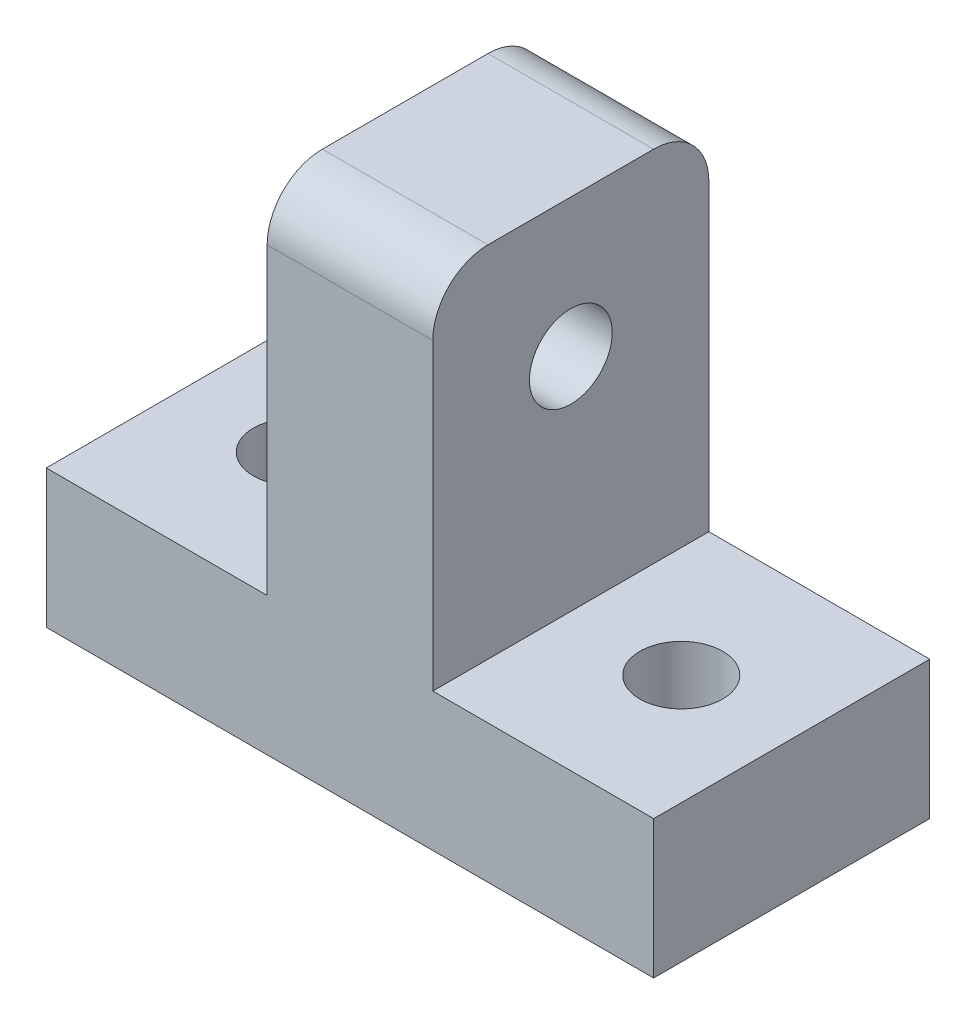
from build123d import *

# Parameters (mm, degrees)
SKETCH1_W           = 22
SKETCH1_H           = 10
SKETCH1_R           = 1.5
BOSS_EXTRUDE1_DEPTH = 5
SKETCH4_W           = 6
SKETCH4_H           = 10
BOSS_EXTRUDE3_DEPTH = 13
CUT_EXTRUDE1_REACH  = 16
SKETCH5_R           = 1.5
FILLET1_R           = 2


with BuildPart() as part:
    # Sketch1 → Boss-Extrude1 (new body)
    with BuildSketch(Plane(origin=(0, 0, 0), x_dir=(1, 0, 0), z_dir=(0, 1, 0))):
        Rectangle(SKETCH1_W, SKETCH1_H)
        with Locations((-7, 0)):
            Circle(SKETCH1_R, mode=Mode.SUBTRACT)
        with Locations((7, 0)):
            Circle(SKETCH1_R, mode=Mode.SUBTRACT)
    extrude(amount=BOSS_EXTRUDE1_DEPTH)

    # Sketch4 → Boss-Extrude3 (add)
    with BuildSketch(Plane(origin=(0, 5, 0), x_dir=(1, 0, 0), z_dir=(0, 1, 0))):
        Rectangle(SKETCH4_W, SKETCH4_H)
    extrude(amount=BOSS_EXTRUDE3_DEPTH)

    # Sketch5 → Cut-Extrude1 (cut, up to next)
    with BuildSketch(Plane(origin=(3, 0, 0), x_dir=(0, 0, -1), z_dir=(1, 0, 0)), mode=Mode.PRIVATE) as cut_extrude1_sk1:
        with Locations((0, 13)):
            Circle(SKETCH5_R)
    cut_extrude1_tool1 = extrude(cut_extrude1_sk1.sketch, amount=-CUT_EXTRUDE1_REACH, mode=Mode.PRIVATE) & part.part
    add(cut_extrude1_tool1.solids().sort_by_distance((3, 13, 0))[0], mode=Mode.SUBTRACT)

    # Fillet1
    fillet1_edges = [part.edges().sort_by_distance(p)[0] for p in [
        (0, 18, -5),
        (0, 18, 5),
    ]]
    fillet(fillet1_edges, radius=FILLET1_R)


solid = part.part
